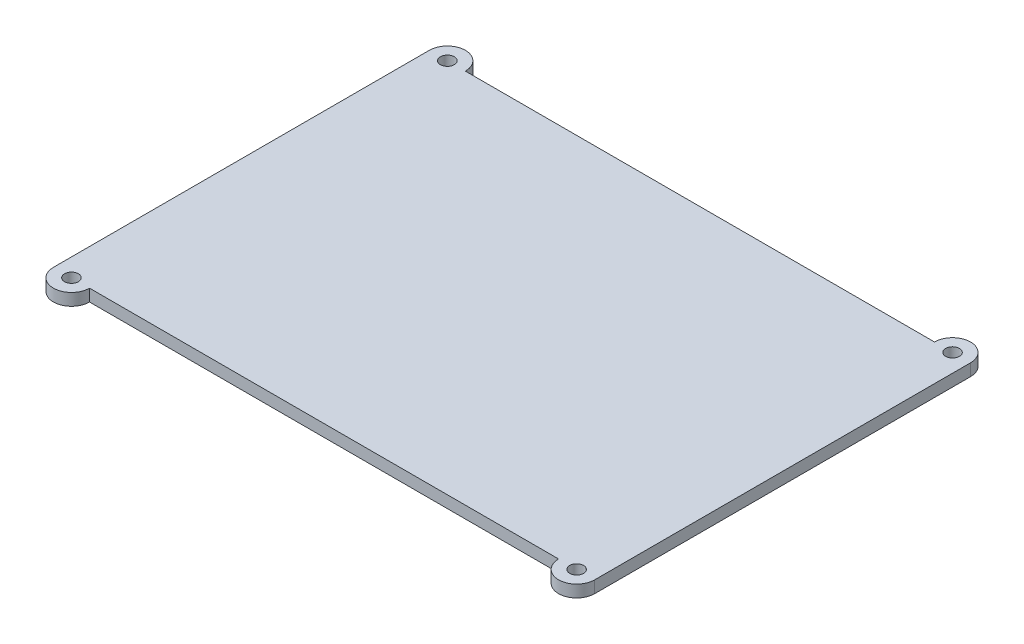
from build123d import *

# Parameters (mm, degrees)
BASE_EXTRUDE_DEPTH   = 2
HOLES_R              = 1.15
HOLES_CUT_DEPTH      = 3
INSIDE_W             = 85.5
INSIDE_H             = 58
INSIDE_EXTRUDE_DEPTH = 2


with BuildPart() as part:
    # Base → Base Extrude (new body)
    with BuildSketch(Plane(origin=(0, 0, 0), x_dir=(1, 0, 0), z_dir=(0, 1, 0))):
        with BuildLine():
            Line((6, 0), (84, 0))
            ThreePointArc((84, 0), (87, -3), (90, 0))
            Line((90, 0), (90, 62.5))
            ThreePointArc((90, 62.5), (87, 65.5), (84, 62.5))
            Line((84, 62.5), (6, 62.5))
            ThreePointArc((6, 62.5), (3, 65.5), (0, 62.5))
            Line((0, 62.5), (0, 0))
            ThreePointArc((0, 0), (3, -3), (6, 0))
        make_face()
    extrude(amount=BASE_EXTRUDE_DEPTH)

    # Holes → Holes Cut (cut, through all)
    with BuildSketch(Plane(origin=(0, 2, 0), x_dir=(1, 0, 0), z_dir=(0, 1, 0))):
        with Locations((3, 62.5)):
            Circle(HOLES_R)
        with Locations((87, 62.5)):
            Circle(HOLES_R)
        with Locations((87, 0)):
            Circle(HOLES_R)
        with Locations((3, 0)):
            Circle(HOLES_R)
    extrude(amount=-HOLES_CUT_DEPTH, mode=Mode.SUBTRACT)

    # Inside → Inside Extrude (add)
    with BuildSketch(Plane.XZ):
        with Locations((45, -31.25)):
            Rectangle(INSIDE_W, INSIDE_H)
    extrude(amount=INSIDE_EXTRUDE_DEPTH)


solid = part.part
